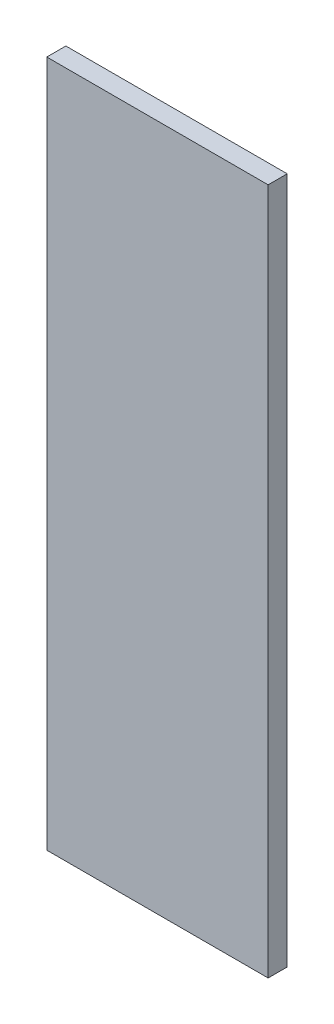
from build123d import *

# Parameters (mm, degrees)
ESQUISSE1_W        = 58
ESQUISSE1_H        = 180
BOSS_EXTRU_2_DEPTH = 5


with BuildPart() as part:
    # Esquisse1 → Boss.-Extru.2 (new body)
    with BuildSketch(Plane.XY):
        with Locations((29, 90)):
            Rectangle(ESQUISSE1_W, ESQUISSE1_H)
    extrude(amount=BOSS_EXTRU_2_DEPTH)


solid = part.part
